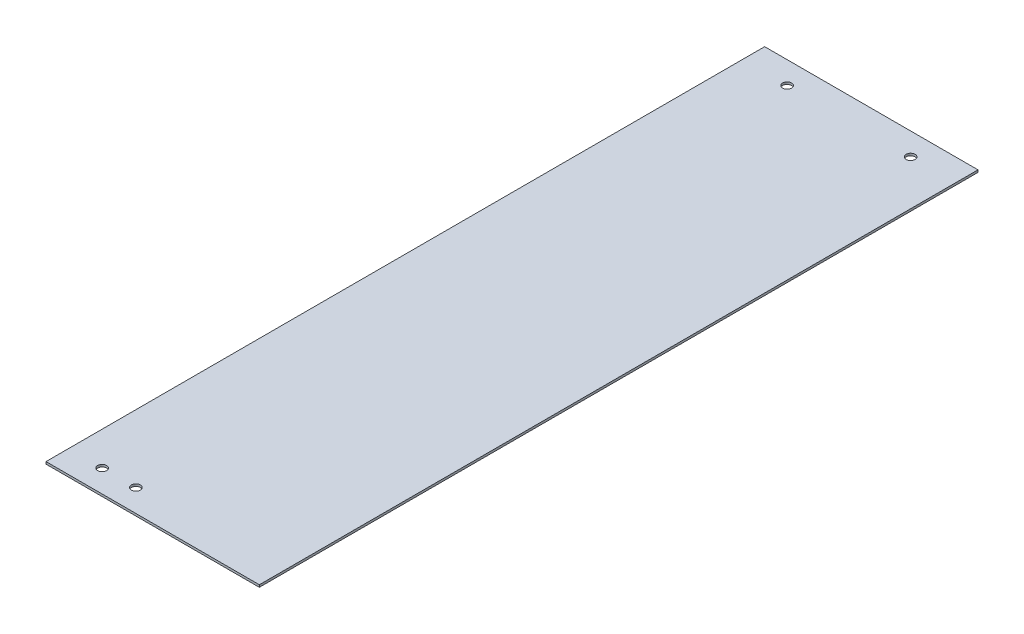
from build123d import *

# Parameters (mm, degrees)
SKETCH1_W               = 95
SKETCH1_H               = 320
SKETCH1_R               = 2
BOSS_EXTRUDE1_DEPTH     = 1
SKETCH2_R               = 2
CUT_EXTRUDE1_DEPTH      = 1
CUT_EXTRUDE1_DEPTH_BACK = 2


with BuildPart() as part:
    # Sketch1 → Boss-Extrude1 (new body)
    with BuildSketch(Plane(origin=(0, 0, 0), x_dir=(1, 0, 0), z_dir=(0, 1, 0))):
        Rectangle(SKETCH1_W, SKETCH1_H)
        with Locations((-27.5, 150)):
            Circle(SKETCH1_R, mode=Mode.SUBTRACT)
        with Locations((27.5, 150)):
            Circle(SKETCH1_R, mode=Mode.SUBTRACT)
    extrude(amount=BOSS_EXTRUDE1_DEPTH)

    # Sketch2 → Cut-Extrude1 (cut, two sides)
    with BuildSketch(Plane(origin=(0, 1, 0), x_dir=(1, 0, 0), z_dir=(0, 1, 0))) as cut_extrude1_sk:
        with Locations((-32.5, -150)):
            Circle(SKETCH2_R)
        with Locations((-17.5, -150)):
            Circle(SKETCH2_R)
    extrude(amount=CUT_EXTRUDE1_DEPTH, mode=Mode.SUBTRACT)
    extrude(cut_extrude1_sk.sketch, amount=-CUT_EXTRUDE1_DEPTH_BACK, mode=Mode.SUBTRACT)


solid = part.part
